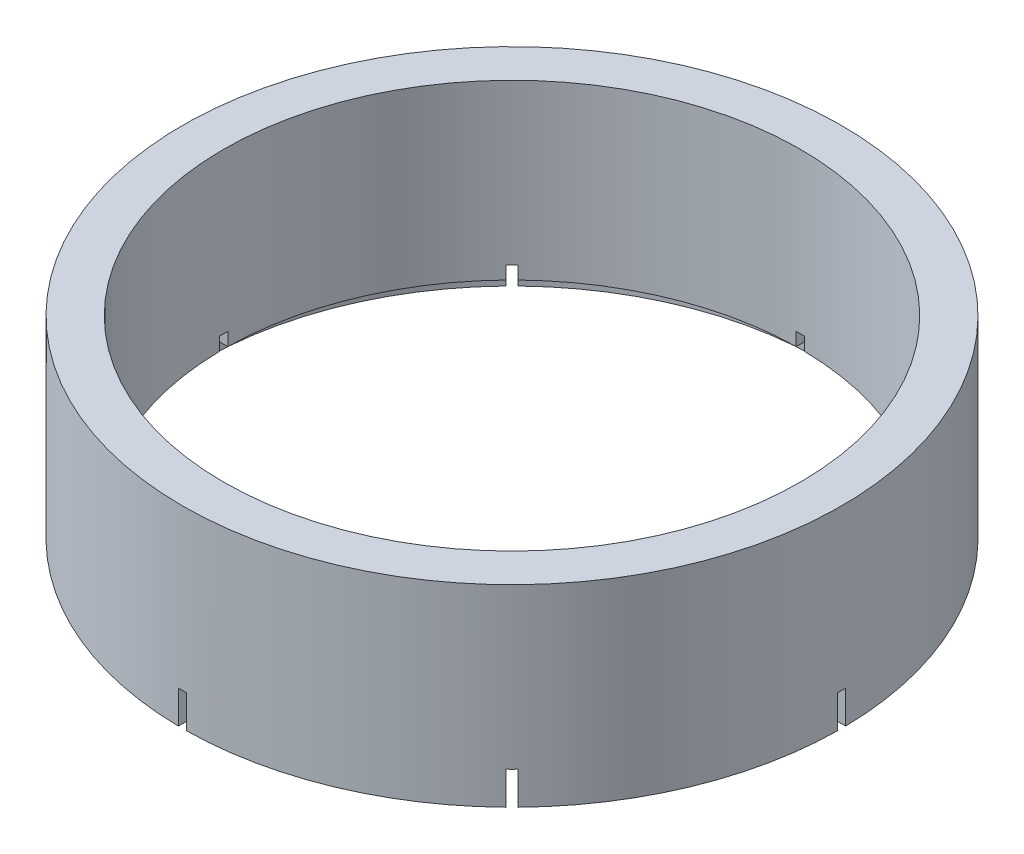
from build123d import *

# Parameters (mm, degrees)
SKETCH1_R           = 40
SKETCH1_R_2         = 35
BOSS_EXTRUDE1_DEPTH = 25.4
SKETCH2_R           = 37.5
SKETCH2_R_2         = 35
CUT_EXTRUDE1_DEPTH  = 4.4
SKETCH3_W           = 1
SKETCH3_H           = 6
CUT_EXTRUDE2_DEPTH  = 41
CIRPATTERN1_COUNT   = 4
CIRPATTERN1_ANGLE   = 135
SKETCH4_R           = 45.877575429
CUT_EXTRUDE3_DEPTH  = 2


with BuildPart() as part:
    # Sketch1 → Boss-Extrude1 (new body)
    with BuildSketch(Plane(origin=(0, 0, 0), x_dir=(1, 0, 0), z_dir=(0, 1, 0))):
        Circle(SKETCH1_R)
        Circle(SKETCH1_R_2, mode=Mode.SUBTRACT)
    extrude(amount=BOSS_EXTRUDE1_DEPTH)

    # Sketch2 → Cut-Extrude1 (cut)
    with BuildSketch(Plane.XZ):
        Circle(SKETCH2_R)
        Circle(SKETCH2_R_2, mode=Mode.SUBTRACT)
    extrude(amount=-CUT_EXTRUDE1_DEPTH, mode=Mode.SUBTRACT)

    # Sketch3 → Cut-Extrude2 (cut, symmetric)
    with BuildSketch(Plane.XY):
        with Locations((0, 3)):
            Rectangle(SKETCH3_W, SKETCH3_H)
    cut_extrude2 = extrude(amount=CUT_EXTRUDE2_DEPTH, both=True, mode=Mode.SUBTRACT)

    # CirPattern1: Cut-Extrude2 ×4 about axis
    cirpattern1_axis = Axis((0, 0, 0), (0, 1, 0))
    for i in range(1, CIRPATTERN1_COUNT):
        add(cut_extrude2.rotate(cirpattern1_axis, i * CIRPATTERN1_ANGLE / (CIRPATTERN1_COUNT - 1)), mode=Mode.SUBTRACT)

    # Sketch4 → Cut-Extrude3 (cut)
    with BuildSketch(Plane.XZ):
        Circle(SKETCH4_R)
    extrude(amount=-CUT_EXTRUDE3_DEPTH, mode=Mode.SUBTRACT)


solid = part.part
